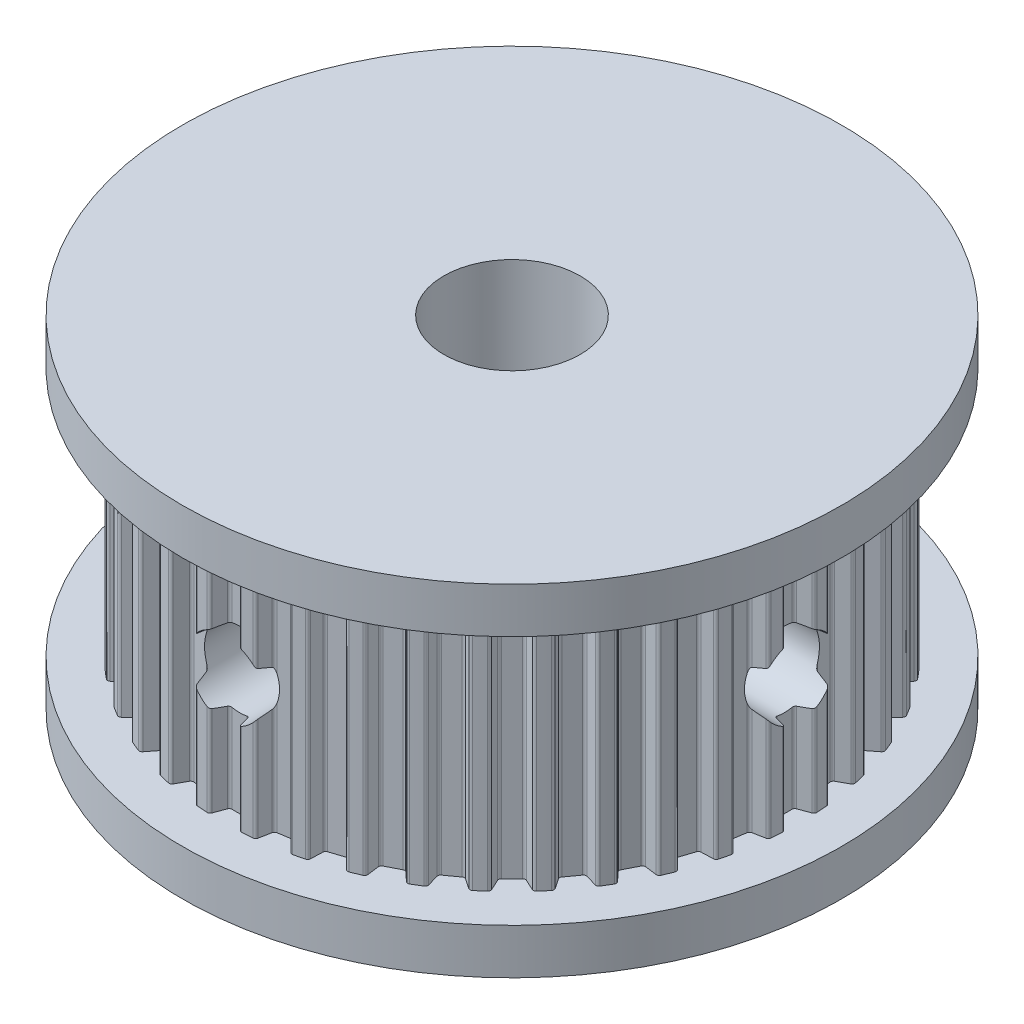
from build123d import *

# Parameters (mm, degrees)
SKETCH_1_R                       = 12.68
EXTRUDE_1_DEPTH                  = 5.5
CUT_EXTRUDE_1_DEPTH              = 12
FILLET_1_R                       = 0.13
PATTERN_CIRCULAR_1_COUNT         = 40
FILLET_1_OF_PATTERN_CIRCULAR_1_R = 0.13
SKETCH_3_R                       = 14.5
EXTRUDE_2_DEPTH                  = 2
SKETCH_4_R                       = 14.5
EXTRUDE_3_DEPTH                  = 2
SKETCH_5_R                       = 3
CUT_EXTRUDE_2_DEPTH              = 16
SKETCH_9_W                       = 1.65
SKETCH_9_H                       = 14.5
PATTERN_CIRCULAR_2_COUNT         = 2
PATTERN_CIRCULAR_2_ANGLE         = 90


with BuildPart() as part:
    # 草圖1 → 填料-伸長1 (new body, symmetric)
    with BuildSketch(Plane(origin=(0, 0, 0), x_dir=(1, 0, 0), z_dir=(0, 1, 0))):
        Circle(SKETCH_1_R)
    extrude(amount=EXTRUDE_1_DEPTH, both=True)

    # 草圖2 → 除料-伸長1 (cut, through all)
    with BuildSketch(Plane.XZ.offset(5.5)):
        with BuildLine():
            Line((0, 11.99), (-0.42, 11.99))
            Line((-0.42, 11.99), (-0.664792189, 12.662561011))
            ThreePointArc((-0.664792189, 12.662561011), (0, 12.68), (0.664792189, 12.662561011))
            Line((0.664792189, 12.662561011), (0.42, 11.99))
            Line((0.42, 11.99), (0, 11.99))
        make_face()
    cut_extrude_1 = extrude(amount=-CUT_EXTRUDE_1_DEPTH, mode=Mode.SUBTRACT)

    # 圓角1
    fillet_1_edges = [part.edges().sort_by_distance(p)[0] for p in [
        (0.42, 0, 11.99),
        (-0.42, 0, 11.99),
        (-0.664792189, 0, 12.662561011),
        (0.664792189, 0, 12.662561011),
    ]]
    fillet(fillet_1_edges, radius=FILLET_1_R)

    # 環狀複製排列1: 除料-伸長1 ×40 about axis
    pattern_circular_1_axis = Axis((0, 0, 0), (0, 1, 0))
    for i in range(1, PATTERN_CIRCULAR_1_COUNT):
        add(cut_extrude_1.rotate(pattern_circular_1_axis, i * 360 / PATTERN_CIRCULAR_1_COUNT), mode=Mode.SUBTRACT)

    # 圓角1 of 環狀複製排列1
    fillet_1_of_pattern_circular_1_edges = [part.edges().sort_by_distance(p)[0] for p in [
        (2.290478339, 0, 11.776680728),
        (1.460820133, 0, 11.908085679),
        (1.324253464, 0, 12.610660283),
        (2.637468451, 0, 12.402667462),
        (4.104557499, 0, 11.273380493),
        (3.305670026, 0, 11.532954768),
        (3.280691602, 0, 12.248243246),
        (4.545201487, 0, 11.837379078),
        (5.817568832, 0, 10.492492215),
        (5.069123352, 0, 10.873844235),
        (5.156348224, 0, 11.584233811),
        (6.341016578, 0, 10.980615135),
        (7.387332313, 0, 9.453243957),
        (6.707758037, 0, 9.946983569),
        (6.90503844, 0, 10.634982094),
        (7.980694797, 0, 9.853472006),
        (8.775195155, 0, 8.181225458),
        (8.181225458, 0, 8.775195155),
        (8.483703693, 0, 9.423861822),
        (9.423861822, 0, 8.483703693),
        (9.946983569, 0, 6.707758037),
        (9.453243957, 0, 7.387332313),
        (9.853472006, 0, 7.980694797),
        (10.634982094, 0, 6.90503844),
        (10.873844235, 0, 5.069123352),
        (10.492492215, 0, 5.817568832),
        (10.980615135, 0, 6.341016578),
        (11.584233811, 0, 5.156348224),
        (11.532954768, 0, 3.305670026),
        (11.273380493, 0, 4.104557499),
        (11.837379078, 0, 4.545201487),
        (12.248243246, 0, 3.280691602),
        (11.908085679, 0, 1.460820133),
        (11.776680728, 0, 2.290478339),
        (12.402667462, 0, 2.637468451),
        (12.610660283, 0, 1.324253464),
        (11.99, 0, -0.42),
        (11.99, 0, 0.42),
        (12.662561011, 0, 0.664792189),
        (12.662561011, 0, -0.664792189),
        (11.776680728, 0, -2.290478339),
        (11.908085679, 0, -1.460820133),
        (12.610660283, 0, -1.324253464),
        (12.402667462, 0, -2.637468451),
        (11.273380493, 0, -4.104557499),
        (11.532954768, 0, -3.305670026),
        (12.248243246, 0, -3.280691602),
        (11.837379078, 0, -4.545201487),
        (10.492492215, 0, -5.817568832),
        (10.873844235, 0, -5.069123352),
        (11.584233811, 0, -5.156348224),
        (10.980615135, 0, -6.341016578),
        (9.453243957, 0, -7.387332313),
        (9.946983569, 0, -6.707758037),
        (10.634982094, 0, -6.90503844),
        (9.853472006, 0, -7.980694797),
        (8.181225458, 0, -8.775195155),
        (8.775195155, 0, -8.181225458),
        (9.423861822, 0, -8.483703693),
        (8.483703693, 0, -9.423861822),
        (6.707758037, 0, -9.946983569),
        (7.387332313, 0, -9.453243957),
        (7.980694797, 0, -9.853472006),
        (6.90503844, 0, -10.634982094),
        (5.069123352, 0, -10.873844235),
        (5.817568832, 0, -10.492492215),
        (6.341016578, 0, -10.980615135),
        (5.156348224, 0, -11.584233811),
        (3.305670026, 0, -11.532954768),
        (4.104557499, 0, -11.273380493),
        (4.545201487, 0, -11.837379078),
        (3.280691602, 0, -12.248243246),
        (1.460820133, 0, -11.908085679),
        (2.290478339, 0, -11.776680728),
        (2.637468451, 0, -12.402667462),
        (1.324253464, 0, -12.610660283),
        (-0.42, 0, -11.99),
        (0.42, 0, -11.99),
        (0.664792189, 0, -12.662561011),
        (-0.664792189, 0, -12.662561011),
        (-2.290478339, 0, -11.776680728),
        (-1.460820133, 0, -11.908085679),
        (-1.324253464, 0, -12.610660283),
        (-2.637468451, 0, -12.402667462),
        (-4.104557499, 0, -11.273380493),
        (-3.305670026, 0, -11.532954768),
        (-3.280691602, 0, -12.248243246),
        (-4.545201487, 0, -11.837379078),
        (-5.817568832, 0, -10.492492215),
        (-5.069123352, 0, -10.873844235),
        (-5.156348224, 0, -11.584233811),
        (-6.341016578, 0, -10.980615135),
        (-7.387332313, 0, -9.453243957),
        (-6.707758037, 0, -9.946983569),
        (-6.90503844, 0, -10.634982094),
        (-7.980694797, 0, -9.853472006),
        (-8.775195155, 0, -8.181225458),
        (-8.181225458, 0, -8.775195155),
        (-8.483703693, 0, -9.423861822),
        (-9.423861822, 0, -8.483703693),
        (-9.946983569, 0, -6.707758037),
        (-9.453243957, 0, -7.387332313),
        (-9.853472006, 0, -7.980694797),
        (-10.634982094, 0, -6.90503844),
        (-10.873844235, 0, -5.069123352),
        (-10.492492215, 0, -5.817568832),
        (-10.980615135, 0, -6.341016578),
        (-11.584233811, 0, -5.156348224),
        (-11.532954768, 0, -3.305670026),
        (-11.273380493, 0, -4.104557499),
        (-11.837379078, 0, -4.545201487),
        (-12.248243246, 0, -3.280691602),
        (-11.908085679, 0, -1.460820133),
        (-11.776680728, 0, -2.290478339),
        (-12.402667462, 0, -2.637468451),
        (-12.610660283, 0, -1.324253464),
        (-11.99, 0, 0.42),
        (-11.99, 0, -0.42),
        (-12.662561011, 0, -0.664792189),
        (-12.662561011, 0, 0.664792189),
        (-11.776680728, 0, 2.290478339),
        (-11.908085679, 0, 1.460820133),
        (-12.610660283, 0, 1.324253464),
        (-12.402667462, 0, 2.637468451),
        (-11.273380493, 0, 4.104557499),
        (-11.532954768, 0, 3.305670026),
        (-12.248243246, 0, 3.280691602),
        (-11.837379078, 0, 4.545201487),
        (-10.492492215, 0, 5.817568832),
        (-10.873844235, 0, 5.069123352),
        (-11.584233811, 0, 5.156348224),
        (-10.980615135, 0, 6.341016578),
        (-9.453243957, 0, 7.387332313),
        (-9.946983569, 0, 6.707758037),
        (-10.634982094, 0, 6.90503844),
        (-9.853472006, 0, 7.980694797),
        (-8.181225458, 0, 8.775195155),
        (-8.775195155, 0, 8.181225458),
        (-9.423861822, 0, 8.483703693),
        (-8.483703693, 0, 9.423861822),
        (-6.707758037, 0, 9.946983569),
        (-7.387332313, 0, 9.453243957),
        (-7.980694797, 0, 9.853472006),
        (-6.90503844, 0, 10.634982094),
        (-5.069123352, 0, 10.873844235),
        (-5.817568832, 0, 10.492492215),
        (-6.341016578, 0, 10.980615135),
        (-5.156348224, 0, 11.584233811),
        (-3.305670026, 0, 11.532954768),
        (-4.104557499, 0, 11.273380493),
        (-4.545201487, 0, 11.837379078),
        (-3.280691602, 0, 12.248243246),
        (-1.460820133, 0, 11.908085679),
        (-2.290478339, 0, 11.776680728),
        (-2.637468451, 0, 12.402667462),
        (-1.324253464, 0, 12.610660283),
    ]]
    fillet(fillet_1_of_pattern_circular_1_edges, radius=FILLET_1_OF_PATTERN_CIRCULAR_1_R)

    # 草圖3 → 填料-伸長2 (add)
    with BuildSketch(Plane(origin=(0, 5.5, 0), x_dir=(1, 0, 0), z_dir=(0, 1, 0))):
        Circle(SKETCH_3_R)
    extrude(amount=EXTRUDE_2_DEPTH)

    # 草圖4 → 填料-伸長3 (add)
    with BuildSketch(Plane.XZ.offset(5.5)):
        Circle(SKETCH_4_R)
    extrude(amount=EXTRUDE_3_DEPTH)

    # 草圖5 → 除料-伸長2 (cut, through all)
    with BuildSketch(Plane.XZ.offset(7.5)):
        Circle(SKETCH_5_R)
    extrude(amount=-CUT_EXTRUDE_2_DEPTH, mode=Mode.SUBTRACT)

    # 草圖9 → M4x0.7 螺紋孔1 (revolve, cut)
    with BuildSketch(Plane.YZ):
        with Locations((0.825, 7.25)):
            Rectangle(SKETCH_9_W, SKETCH_9_H)
    m4x0_7_1 = revolve(axis=Axis((0, 0, -6.35), (0, 0, 1)), mode=Mode.SUBTRACT)

    # 環狀複製排列2: M4x0.7 螺紋孔1 ×2 about axis
    pattern_circular_2_axis = Axis((0, 7.5, 0), (0, 1, 0))
    for i in range(1, PATTERN_CIRCULAR_2_COUNT):
        add(m4x0_7_1.rotate(pattern_circular_2_axis, i * PATTERN_CIRCULAR_2_ANGLE / (PATTERN_CIRCULAR_2_COUNT - 1)), mode=Mode.SUBTRACT)


solid = part.part
